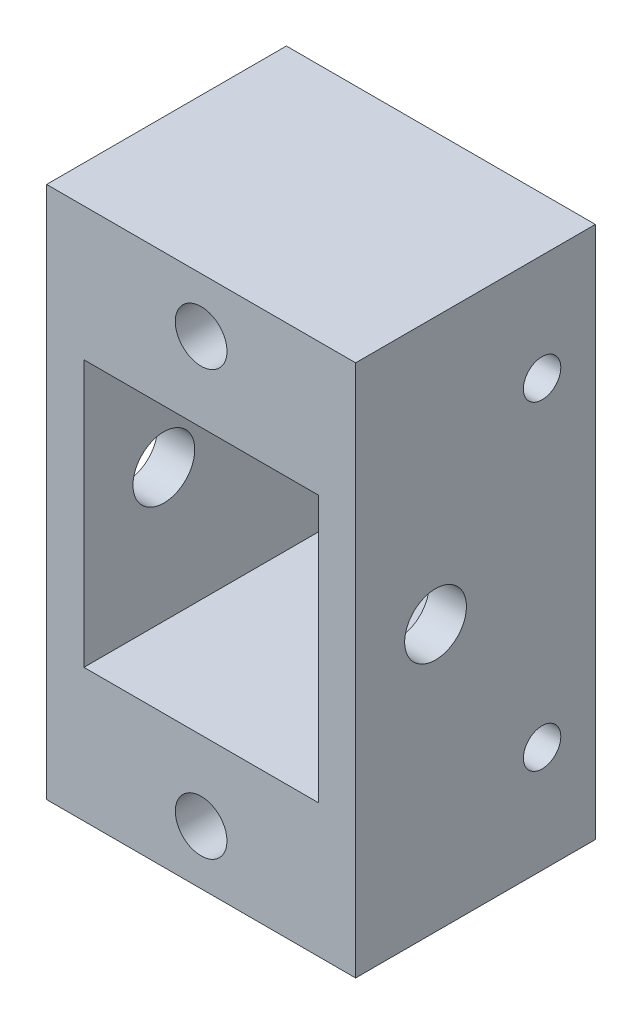
from build123d import *

# Parameters (mm, degrees)
SKETCH2_W           = 29
SKETCH2_H           = 50
SKETCH2_R           = 2.425
SKETCH2_W_2         = 22
SKETCH2_H_2         = 25
BOSS_EXTRUDE1_DEPTH = 22.5
SKETCH3_R           = 1.755
SKETCH3_R_2         = 2.9
CUT_EXTRUDE1_DEPTH  = 30


with BuildPart() as part:
    # Sketch2 → Boss-Extrude1 (new body)
    with BuildSketch(Plane.XY):
        Rectangle(SKETCH2_W, SKETCH2_H)
        with Locations((0, 19.9)):
            Circle(SKETCH2_R, mode=Mode.SUBTRACT)
        with Locations((0, -19.9)):
            Circle(SKETCH2_R, mode=Mode.SUBTRACT)
        Rectangle(SKETCH2_W_2, SKETCH2_H_2, mode=Mode.SUBTRACT)
    extrude(amount=BOSS_EXTRUDE1_DEPTH)

    # Sketch3 → Cut-Extrude1 (cut)
    with BuildSketch(Plane(origin=(14.5, 0, 0), x_dir=(0, 0, -1), z_dir=(1, 0, 0))):
        with Locations((-5, 15)):
            Circle(SKETCH3_R)
        with Locations((-5, -15)):
            Circle(SKETCH3_R)
        with Locations((-15, 0)):
            Circle(SKETCH3_R_2)
    extrude(amount=-CUT_EXTRUDE1_DEPTH, mode=Mode.SUBTRACT)


solid = part.part
